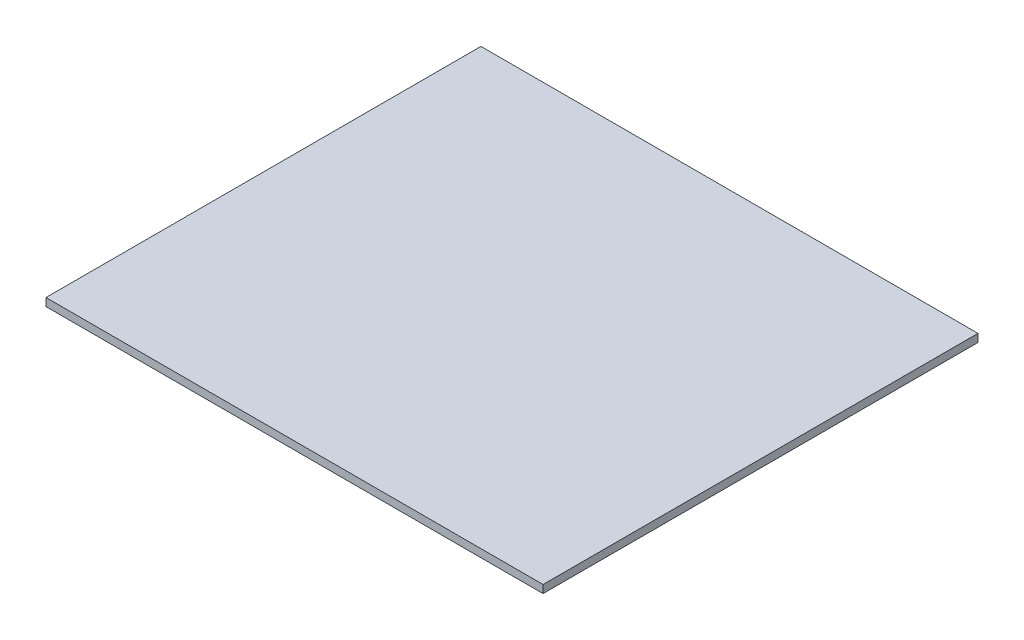
from build123d import *

# Parameters (mm, degrees)
SKETCH1_W           = 400
SKETCH1_H           = 350
BOSS_EXTRUDE1_DEPTH = 6.35


with BuildPart() as part:
    # Sketch1 → Boss-Extrude1 (new body)
    with BuildSketch(Plane(origin=(0, 0, 0), x_dir=(1, 0, 0), z_dir=(0, 1, 0))):
        with Locations((200, 175)):
            Rectangle(SKETCH1_W, SKETCH1_H)
    extrude(amount=BOSS_EXTRUDE1_DEPTH)


solid = part.part
